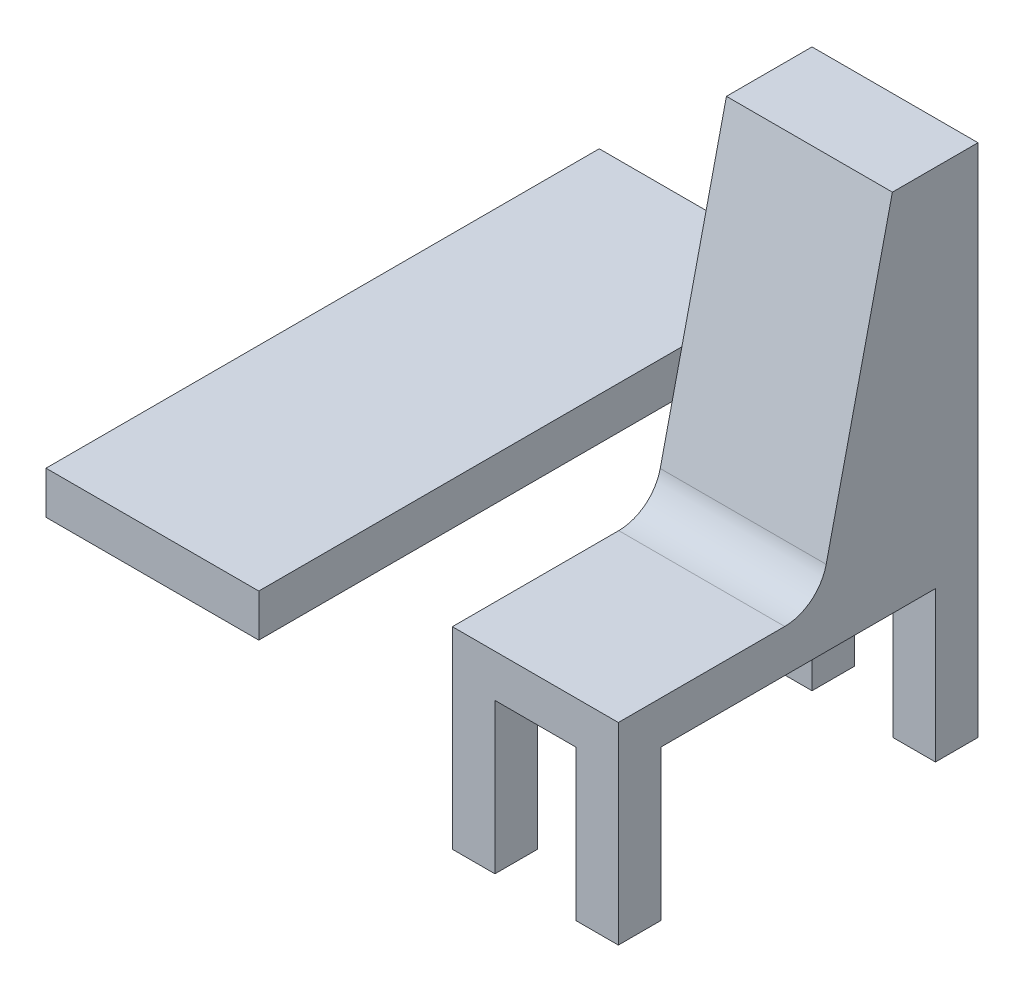
from build123d import *

# Parameters (mm, degrees)
BOSS_EXTRUDE1_DEPTH     = 195
SKETCH2_W               = 645.093387862
SKETCH2_H               = 353.001731878
CUT_EXTRUDE1_DEPTH      = 1
CUT_EXTRUDE1_DEPTH_BACK = 391
FILLET1_R               = 100
SKETCH3_W               = 190
SKETCH3_H               = 353.001731878
CUT_EXTRUDE2_DEPTH      = 1
CUT_EXTRUDE2_DEPTH_BACK = 846.093387862
SKETCH4_W               = 1300
SKETCH4_H               = 100
BOSS_EXTRUDE2_DEPTH     = 500


with BuildPart() as part:
    # Sketch1 → Boss-Extrude1 (new body, symmetric)
    with BuildSketch(Plane(origin=(0, 0, 0), x_dir=(0, 0, -1), z_dir=(1, 0, 0))):
        Polygon((254.379010846, 460.67890474), (81.072942142, -296.617917801), (-389.549913064, -296.617917801), (-389.549913064, -749.619649679), (455.543474798, -749.619649679), (455.543474798, 460.67890474), align=None)
    extrude(amount=BOSS_EXTRUDE1_DEPTH, both=True)

    # Sketch2 → Cut-Extrude1 (cut, two sides)
    with BuildSketch(Plane.ZY.offset(195)) as cut_extrude1_sk:
        with Locations((-32.996780867, -573.11878374)):
            Rectangle(SKETCH2_W, SKETCH2_H)
    extrude(amount=CUT_EXTRUDE1_DEPTH, mode=Mode.SUBTRACT)
    extrude(cut_extrude1_sk.sketch, amount=-CUT_EXTRUDE1_DEPTH_BACK, mode=Mode.SUBTRACT)

    # Fillet1
    fillet1_edges = [part.edges().sort_by_distance(p)[0] for p in [
        (0, -296.617917801, -81.072942142),
    ]]
    fillet(fillet1_edges, radius=FILLET1_R)

    # Sketch3 → Cut-Extrude2 (cut, two sides)
    with BuildSketch(Plane(origin=(0, 0, -455.543474798), x_dir=(-1, 0, 0), z_dir=(0, 0, -1))) as cut_extrude2_sk:
        with Locations((0, -573.11878374)):
            Rectangle(SKETCH3_W, SKETCH3_H)
    extrude(amount=CUT_EXTRUDE2_DEPTH, mode=Mode.SUBTRACT)
    extrude(cut_extrude2_sk.sketch, amount=-CUT_EXTRUDE2_DEPTH_BACK, mode=Mode.SUBTRACT)

    # Sketch4 → Boss-Extrude2 (add)
    with BuildSketch(Plane.ZY.offset(195)):
        with Locations((194.456525202, -46.617917801)):
            Rectangle(SKETCH4_W, SKETCH4_H)
    extrude(amount=BOSS_EXTRUDE2_DEPTH)


solid = part.part
